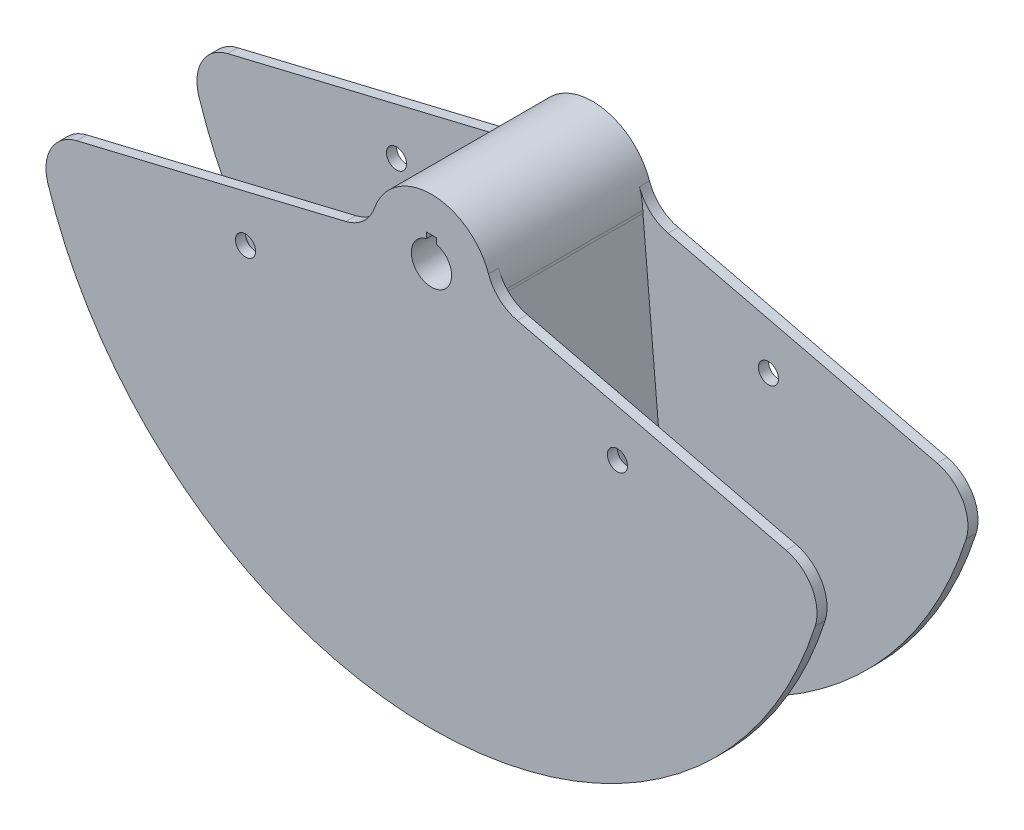
from build123d import *

# Parameters (mm, degrees)
SKETCH1_R               = 12.7
BOSS_EXTRUDE1_DEPTH     = 44.45
SKETCH5_R               = 12.7
SKETCH5_R_2             = 6.35
BOSS_EXTRUDE2_DEPTH     = 6.35
SKETCH8_W               = 6.35
SKETCH8_H               = 6.35
CUT_EXTRUDE1_DEPTH      = 51.8
CUT_EXTRUDE1_DEPTH_BACK = 51.8


with BuildPart() as part:
    # Sketch1 → Boss-Extrude1 (new body, symmetric)
    with BuildSketch(Plane.XY):
        with BuildLine():
            Line((-59.699595301, -246.884504011), (-38.184359795, -0.964236874))
            ThreePointArc((-38.184359795, -0.964236874), (-38.124009824, -0.108037848), (-38.092623076, 0.749711395))
            ThreePointArc((-38.092623076, 0.749711395), (0, 38.1), (38.092623076, 0.749711395))
            ThreePointArc((38.092623076, 0.749711395), (38.124009824, -0.108037848), (38.184359795, -0.964236874))
            Line((38.184359795, -0.964236874), (59.699595301, -246.884504011))
            ThreePointArc((59.699595301, -246.884504011), (0, -254), (-59.699595301, -246.884504011))
        make_face()
        Circle(SKETCH1_R, mode=Mode.SUBTRACT)
    extrude(amount=BOSS_EXTRUDE1_DEPTH, both=True)

    # Sketch5 → Boss-Extrude2 (add)
    with BuildSketch(Plane.XY.offset(44.45)):
        with BuildLine():
            Line((-223.779910529, -44.577802506), (-54.04268144, -3.827499177))
            ThreePointArc((-54.04268144, -3.827499177), (-42.924981025, 2.041131203), (-35.983316209, 12.522418081))
            ThreePointArc((-35.983316209, 12.522418081), (0, 38.1), (35.983316209, 12.522418081))
            ThreePointArc((35.983316209, 12.522418081), (42.924981025, 2.041131203), (54.04268144, -3.827499177))
            Line((54.04268144, -3.827499177), (223.779910529, -44.577802506))
            ThreePointArc((223.779910529, -44.577802506), (239.972758508, -56.795566669), (242.055998097, -76.973331649))
            ThreePointArc((242.055998097, -76.973331649), (0, -254), (-242.055998097, -76.973331649))
            ThreePointArc((-242.055998097, -76.973331649), (-239.972758508, -56.795566669), (-223.779910529, -44.577802506))
        make_face()
        Circle(SKETCH5_R, mode=Mode.SUBTRACT)
        with Locations((-117.332700629, -48.60079591)):
            Circle(SKETCH5_R_2, mode=Mode.SUBTRACT)
        with Locations((117.332700629, -48.60079591)):
            Circle(SKETCH5_R_2, mode=Mode.SUBTRACT)
    boss_extrude2 = extrude(amount=BOSS_EXTRUDE2_DEPTH)

    # Mirror1: Boss-Extrude2 across plane
    add(boss_extrude2.mirror(Plane.XY))

    # Sketch8 → Cut-Extrude1 (cut, two sides)
    with BuildSketch(Plane.XY) as cut_extrude1_sk:
        with Locations((0, 12.7)):
            Rectangle(SKETCH8_W, SKETCH8_H)
    extrude(amount=CUT_EXTRUDE1_DEPTH, mode=Mode.SUBTRACT)
    extrude(cut_extrude1_sk.sketch, amount=-CUT_EXTRUDE1_DEPTH_BACK, mode=Mode.SUBTRACT)


solid = part.part
